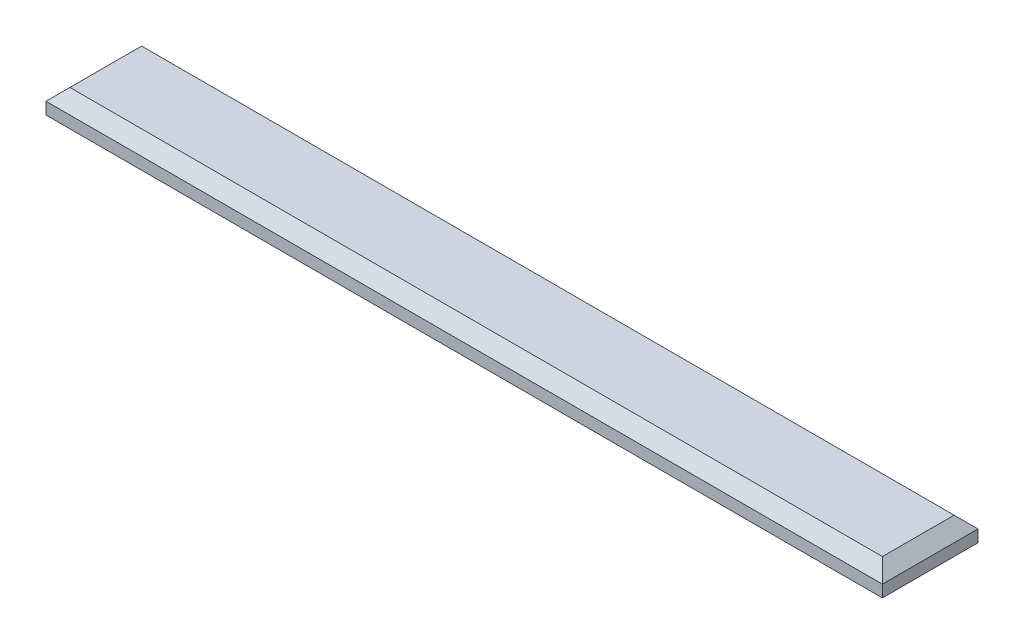
from build123d import *

# Parameters (mm, degrees)
SKETCH1_W           = 70
SKETCH1_H           = 8
BOSS_EXTRUDE1_DEPTH = 2
CHAMFER1_SIZE       = 1


with BuildPart() as part:
    # Sketch1 → Boss-Extrude1 (new body)
    with BuildSketch(Plane(origin=(0, 0, 0), x_dir=(1, 0, 0), z_dir=(0, 1, 0))):
        with Locations((35, 4)):
            Rectangle(SKETCH1_W, SKETCH1_H)
    extrude(amount=BOSS_EXTRUDE1_DEPTH)

    # Chamfer1
    chamfer1_edges = [part.edges().sort_by_distance(p)[0] for p in [
        (70, 2, -4),
        (35, 2, -8),
        (0, 2, -4),
        (35, 2, 0),
    ]]
    chamfer(chamfer1_edges, length=CHAMFER1_SIZE)


solid = part.part
